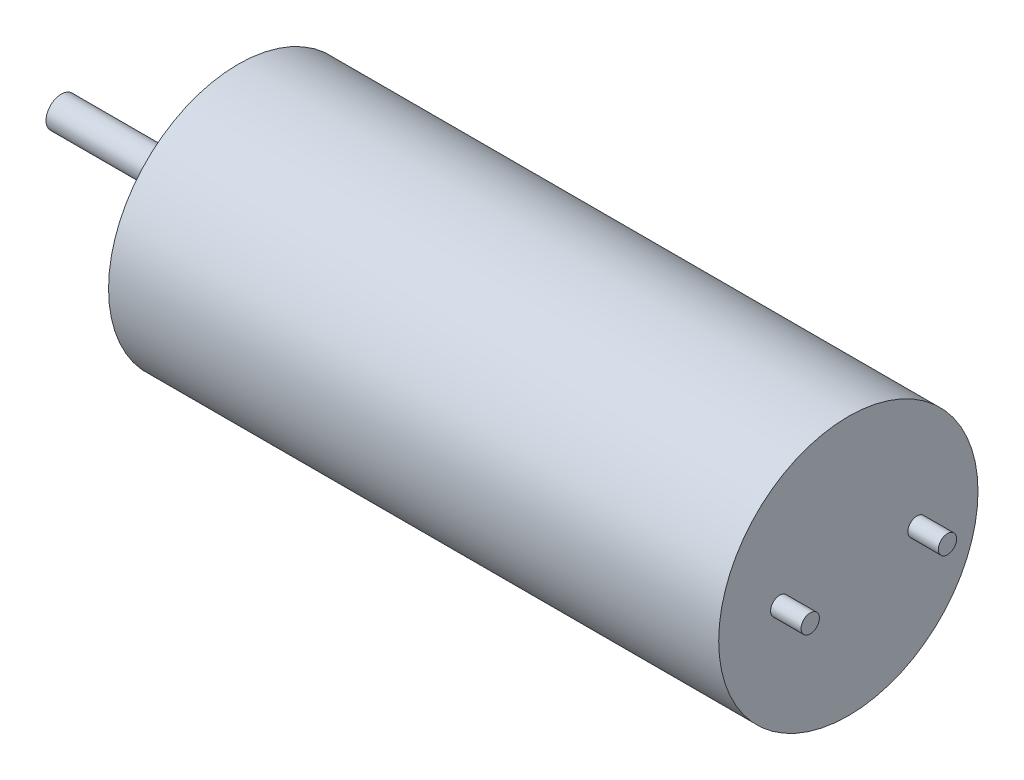
from build123d import *

# Parameters (mm, degrees)
SKETCH1_R           = 4.25
BOSS_EXTRUDE1_DEPTH = 20
SKETCH2_R           = 1.2
BOSS_EXTRUDE2_DEPTH = 0.8
SKETCH3_R           = 0.5
BOSS_EXTRUDE3_DEPTH = 5
SKETCH4_R           = 0.3
BOSS_EXTRUDE4_DEPTH = 1


with BuildPart() as part:
    # Sketch1 → Boss-Extrude1 (new body)
    with BuildSketch(Plane(origin=(0, 0, 0), x_dir=(0, 0, -1), z_dir=(1, 0, 0))):
        Circle(SKETCH1_R)
    extrude(amount=BOSS_EXTRUDE1_DEPTH)

    # Sketch2 → Boss-Extrude2 (add)
    with BuildSketch(Plane.ZY):
        Circle(SKETCH2_R)
    extrude(amount=BOSS_EXTRUDE2_DEPTH)

    # Sketch3 → Boss-Extrude3 (add)
    with BuildSketch(Plane.ZY.offset(0.8)):
        Circle(SKETCH3_R)
    extrude(amount=BOSS_EXTRUDE3_DEPTH)

    # Sketch4 → Boss-Extrude4 (add)
    with BuildSketch(Plane(origin=(20, 0, 0), x_dir=(0, 0, -1), z_dir=(1, 0, 0))):
        with Locations((-2.25, 0)):
            Circle(SKETCH4_R)
        with Locations((2.25, 0)):
            Circle(SKETCH4_R)
    extrude(amount=BOSS_EXTRUDE4_DEPTH)


solid = part.part
